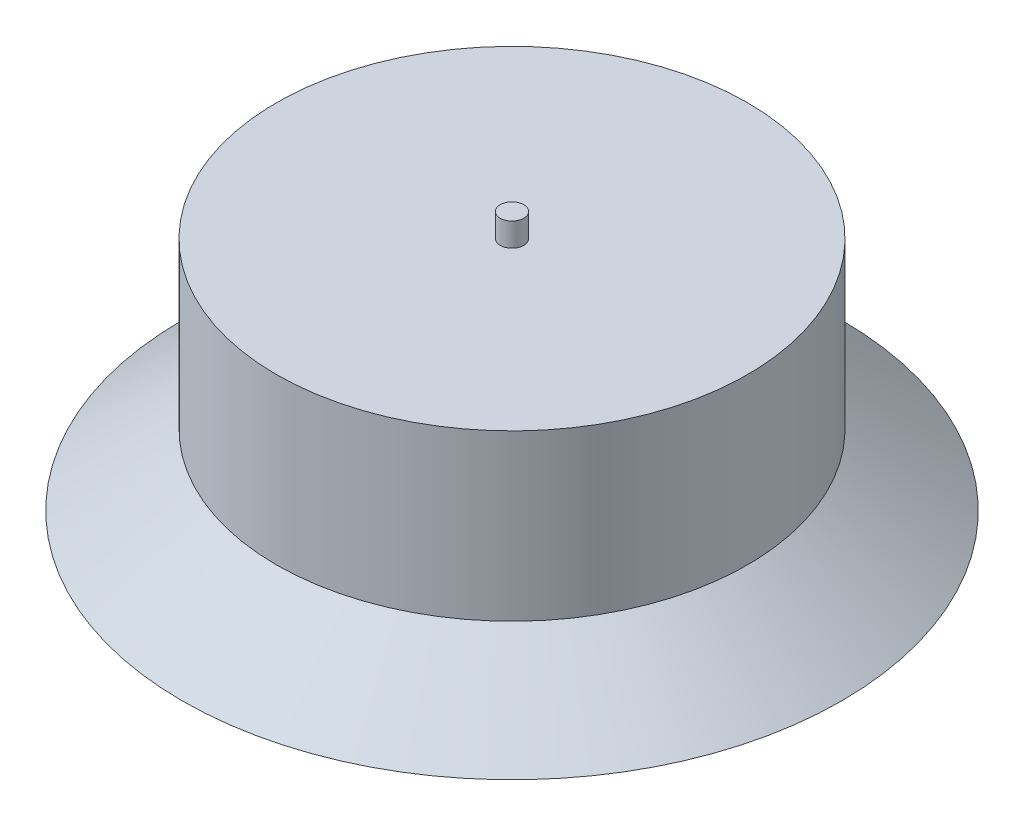
from build123d import *

# Parameters (mm, degrees)
SKETCH1_R           = 100
BOSS_EXTRUDE1_DEPTH = 100
SKETCH3_R           = 5
BOSS_EXTRUDE2_DEPTH = 10


with BuildPart() as part:
    # Sketch1 → Boss-Extrude1 (new body)
    with BuildSketch(Plane(origin=(0, 0, 0), x_dir=(1, 0, 0), z_dir=(0, 1, 0))):
        Circle(SKETCH1_R)
    extrude(amount=BOSS_EXTRUDE1_DEPTH)

    # Sketch2 → Revolve1 (revolve)
    with BuildSketch(Plane(origin=(0, 0, 0), x_dir=(0, 0, -1), z_dir=(1, 0, 0))):
        Polygon((-100, 0), (-140, 0), (-100, 30), align=None)
    revolve(axis=Axis((0, 0, 0), (0, 1, 0)))

    # Sketch3 → Boss-Extrude2 (add)
    with BuildSketch(Plane(origin=(0, 100, 0), x_dir=(1, 0, 0), z_dir=(0, 1, 0))):
        Circle(SKETCH3_R)
    extrude(amount=BOSS_EXTRUDE2_DEPTH)


solid = part.part
